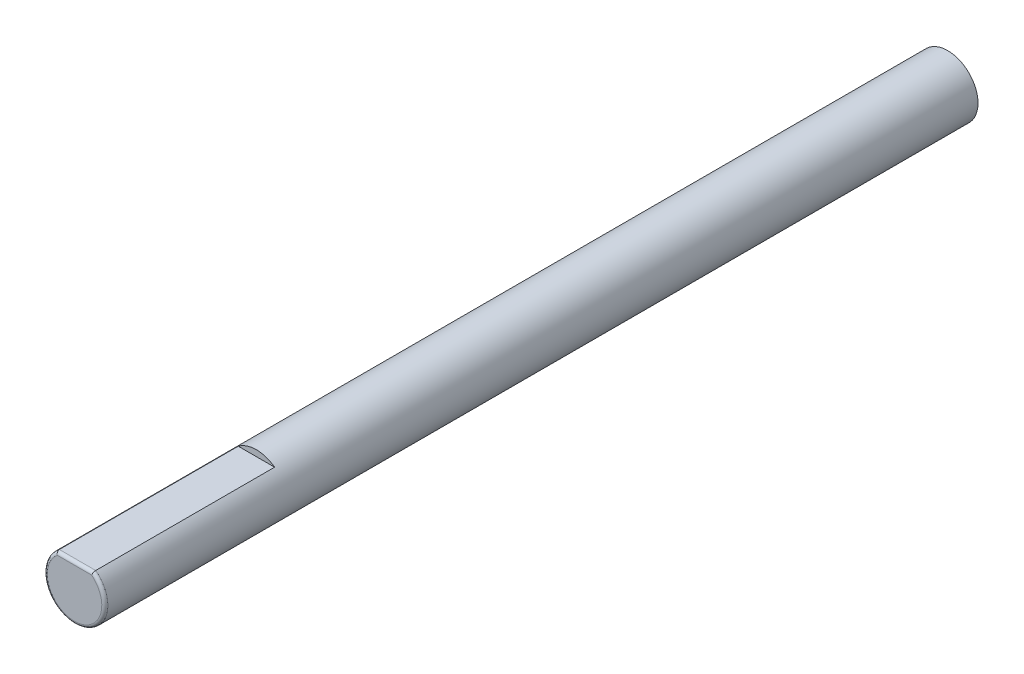
from build123d import *

# Parameters (mm, degrees)
SKETCH1_R        = 2.5
SHAFT_BODY_DEPTH = 36
D_CUT_DEPTH      = 15
FILLET_2_R       = 0.25


with BuildPart() as part:
    # Sketch1 → Shaft Body (new body, symmetric)
    with BuildSketch(Plane.XY):
        Circle(SKETCH1_R)
    extrude(amount=SHAFT_BODY_DEPTH, both=True)

    # Sketch2 → D Cut (cut)
    with BuildSketch(Plane.XY.offset(36)):
        with BuildLine():
            Line((-1.5, 2), (1.5, 2))
            ThreePointArc((1.5, 2), (0, 2.5), (-1.5, 2))
        make_face()
    extrude(amount=-D_CUT_DEPTH, mode=Mode.SUBTRACT)

    # Fillet 2
    fillet_2_edges = [part.edges().sort_by_distance(p)[0] for p in [
        (-1.118033989, -2.236067977, 36),
        (0, 2, 36),
    ]]
    fillet(fillet_2_edges, radius=FILLET_2_R)


solid = part.part
